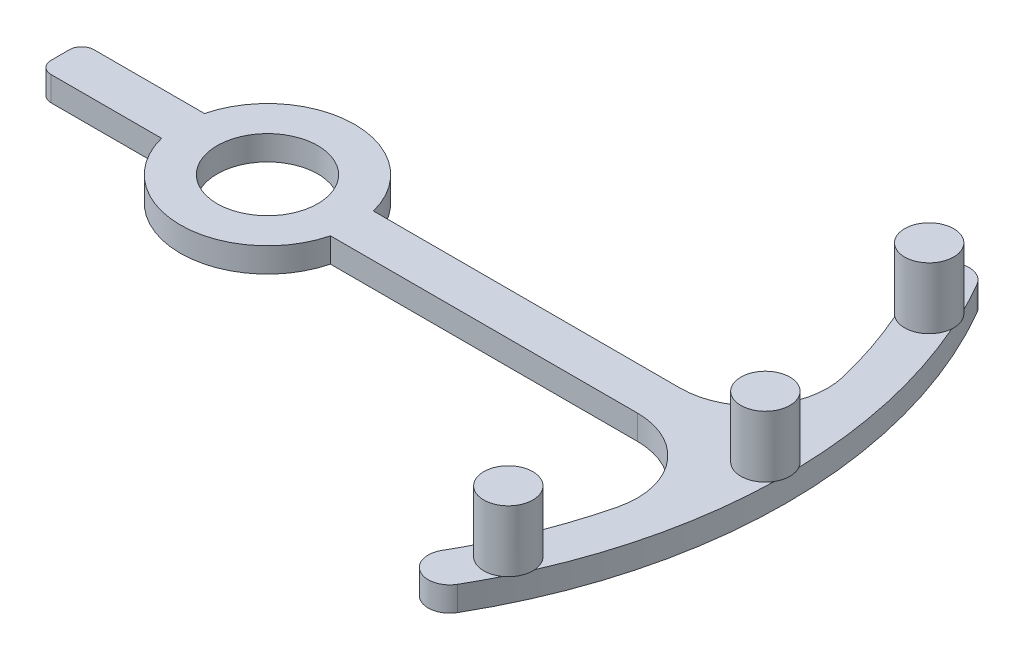
from build123d import *

# Parameters (mm, degrees)
SKETCH1_R           = 4.1
BOSS_EXTRUDE1_DEPTH = 2
SKETCH2_R           = 2
BOSS_EXTRUDE2_DEPTH = 5


with BuildPart() as part:
    # Sketch1 → Boss-Extrude1 (new body)
    with BuildSketch(Plane(origin=(0, 0, 0), x_dir=(1, 0, 0), z_dir=(0, 1, 0))):
        with BuildLine():
            Line((6.880964228, 1.749997239), (31.880964166, 1.749997239))
            ThreePointArc((31.880964166, 1.749997239), (36.598148239, 4.042144166), (37.711172654, 9.167272434))
            ThreePointArc((37.711172654, 9.167272434), (36.026057764, 14.43241452), (33.609947488, 19.40471223))
            ThreePointArc((33.609947488, 19.40471223), (34.250491945, 21.795256686), (36.641036401, 21.15471223))
            ThreePointArc((36.641036401, 21.15471223), (42.309424459, 0), (36.641036401, -21.15471223))
            ThreePointArc((36.641036401, -21.15471223), (34.250491945, -21.795256686), (33.609947488, -19.40471223))
            ThreePointArc((33.609947488, -19.40471223), (36.026056514, -14.432417639), (37.711171067, -9.167278965))
            ThreePointArc((37.711171067, -9.167278965), (36.598147218, -4.042150095), (31.880962823, -1.750002761))
            Line((31.880962823, -1.750002761), (6.880962823, -1.750002761))
            ThreePointArc((6.880962823, -1.750002761), (-0.000729594, -7.100011163), (-6.881322337, -1.748588554))
            Line((-6.881322337, -1.748588554), (-15.881322337, -1.748588554))
            ThreePointArc((-15.881322337, -1.748588554), (-16.588429118, -1.455695335), (-16.881322337, -0.748588554))
            Line((-16.881322337, -0.748588554), (-16.881322337, 0.748588554))
            ThreePointArc((-16.881322337, 0.748588554), (-16.588429118, 1.455695335), (-15.881322337, 1.748588554))
            Line((-15.881322337, 1.748588554), (-6.881322337, 1.748588554))
            ThreePointArc((-6.881322337, 1.748588554), (-0.000726746, 7.100011163), (6.880964228, 1.749997239))
        make_face()
        Circle(SKETCH1_R, mode=Mode.SUBTRACT)
    extrude(amount=BOSS_EXTRUDE1_DEPTH)

    # Sketch2 → Boss-Extrude2 (add)
    with BuildSketch(Plane(origin=(0, 2, 0), x_dir=(1, 0, 0), z_dir=(0, 1, 0))):
        with Locations((36.759322225, 17.141153462)):
            Circle(SKETCH2_R)
        with Locations((40.559424459, 0)):
            Circle(SKETCH2_R)
        with Locations((36.759322225, -17.141153462)):
            Circle(SKETCH2_R)
    extrude(amount=BOSS_EXTRUDE2_DEPTH)


solid = part.part
